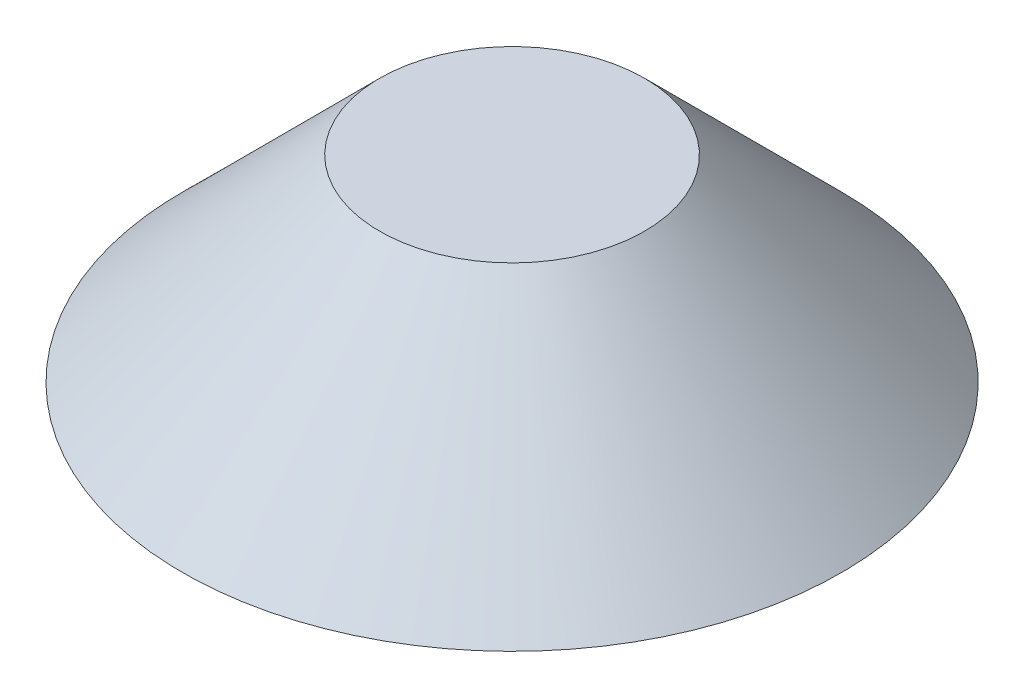
from build123d import *


with BuildPart() as part:
    # Sketch4 → Revolve1 (revolve)
    with BuildSketch(Plane(origin=(0, 0, 0), x_dir=(0, 0, -1), z_dir=(1, 0, 0))):
        Polygon((0, 0), (-12.5, 0), (-5.025947361, 7.474052639), (0, 7.474052639), align=None)
    revolve(axis=Axis((0, 0, 0), (0, 1, 0)))


solid = part.part
